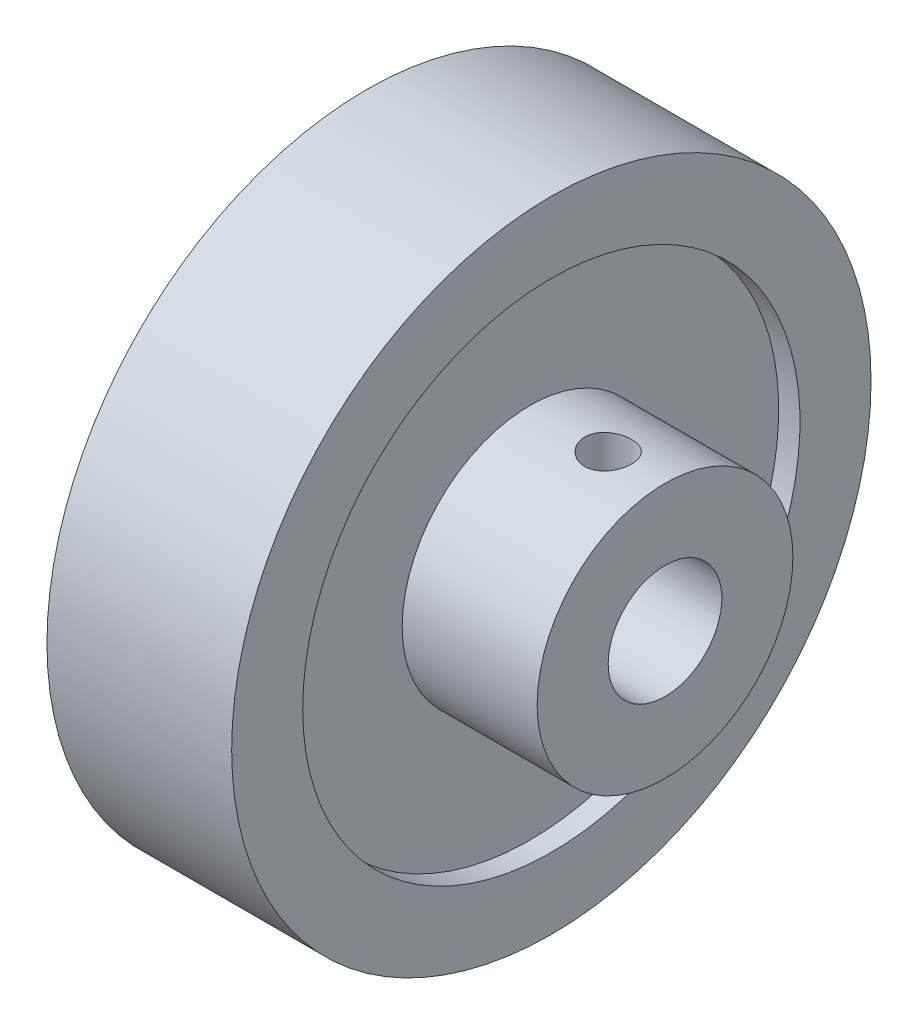
from build123d import *

# Parameters (mm, degrees)
SKETCH1_W              = 8
SKETCH1_H              = 5
SKETCH1_W_2            = 10
SKETCH1_H_2            = 8.5
M4_TAPPED_HOLE1_REACH  = 43.337
M4_TAPPED_HOLE1_BORE_R = 1.65


with BuildPart() as part:
    # Sketch1 → Revolve1 (revolve)
    with BuildSketch(Plane.XY, mode=Mode.PRIVATE) as revolve1_sk:
        Polygon((-6.5, 9), (-6.5, 4), (6.5, 4), (6.5, 9), (5, 9), (-5, 9), align=None)
        with Locations((10.5, 6.5)):
            Rectangle(SKETCH1_W, SKETCH1_H)
        with Locations((0, 13.25)):
            Rectangle(SKETCH1_W_2, SKETCH1_H_2)
        Polygon((-6.5, 17.5), (-5, 17.5), (5, 17.5), (6.5, 17.5), (6.5, 22.5), (-6.5, 22.5), align=None)
    revolve(revolve1_sk.sketch.rotate(Axis((0, 0, 0), (1, 0, 0)), 90), axis=Axis((0, 0, 0), (1, 0, 0)))

    # M4 Tapped Hole1 bore → M4 Tapped Hole1 (cut, up to next)
    with BuildSketch(Plane(origin=(0, 9, 0), x_dir=(1, 0, 0), z_dir=(0, 1, 0)), mode=Mode.PRIVATE) as m4_tapped_hole1_sk1:
        with Locations((10.5, 0)):
            Circle(M4_TAPPED_HOLE1_BORE_R)
    m4_tapped_hole1_tool1 = extrude(m4_tapped_hole1_sk1.sketch, amount=-M4_TAPPED_HOLE1_REACH, mode=Mode.PRIVATE) & part.part
    add(m4_tapped_hole1_tool1.solids().sort_by_distance((10.5, 9, 0))[0], mode=Mode.SUBTRACT)


solid = part.part
